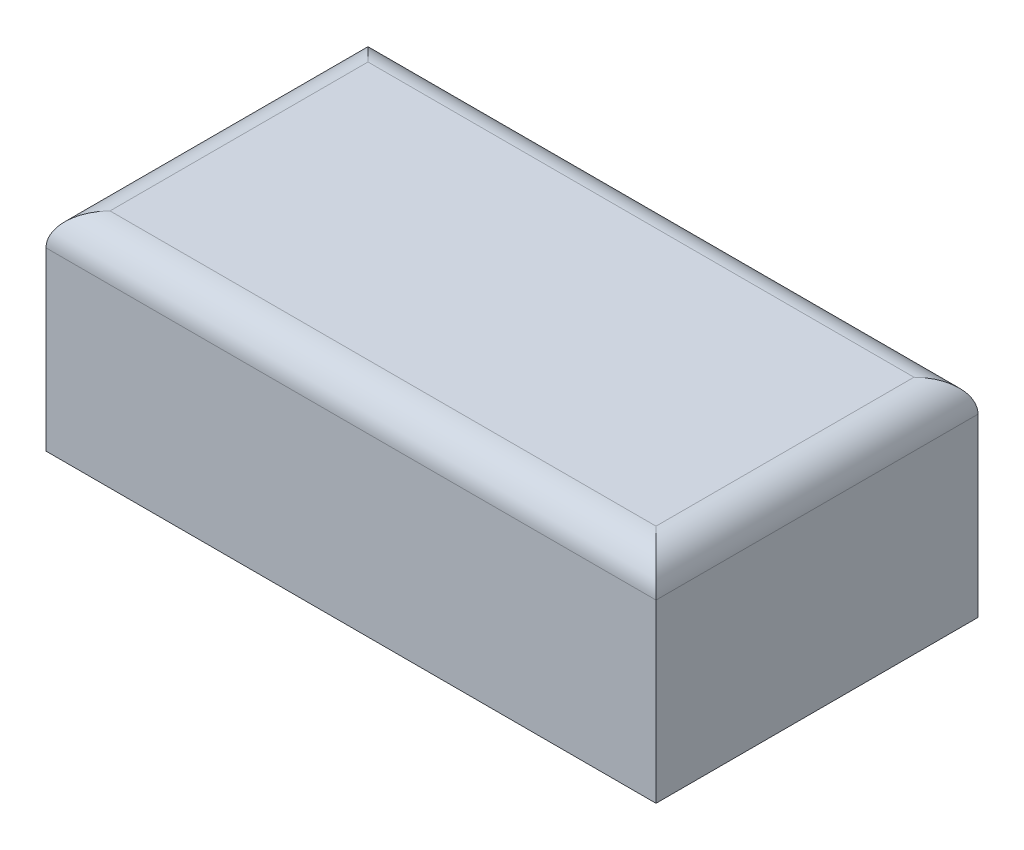
from build123d import *

# Parameters (mm, degrees)
BOSS_EXTRUDE1_START = 650
SKETCH1_W           = 1906
SKETCH1_H           = 1006
BOSS_EXTRUDE1_DEPTH = 2
SKETCH2_W           = 1906
SKETCH2_H           = 1006
SKETCH2_W_2         = 1900
SKETCH2_H_2         = 1002.833158448
BOSS_EXTRUDE2_DEPTH = 648
FILLET1_R           = 100
SKETCH3_W           = 1400
SKETCH3_H           = 560
CUT_EXTRUDE1_DEPTH  = 143


with BuildPart() as part:
    # Sketch1 → Boss-Extrude1 (new body)
    with BuildSketch(Plane(origin=(0, 0, 0), x_dir=(1, 0, 0), z_dir=(0, 1, 0)).offset(BOSS_EXTRUDE1_START)):
        Rectangle(SKETCH1_W, SKETCH1_H)
    extrude(amount=BOSS_EXTRUDE1_DEPTH)

    # Sketch2 → Boss-Extrude2 (add)
    with BuildSketch(Plane.XZ.offset(-650)):
        Rectangle(SKETCH2_W, SKETCH2_H)
        Rectangle(SKETCH2_W_2, SKETCH2_H_2, mode=Mode.SUBTRACT)
    extrude(amount=BOSS_EXTRUDE2_DEPTH)

    # Fillet1
    fillet1_edges = [part.edges().sort_by_distance(p)[0] for p in [
        (953, 652, 0),
        (0, 652, -503),
        (0, 650, 501.416579224),
        (-950, 650, 0),
        (0, 650, -501.416579224),
        (950, 650, 0),
        (-953, 652, 0),
        (0, 652, 503),
    ]]
    fillet(fillet1_edges, radius=FILLET1_R)

    # Sketch3 → Cut-Extrude1 (cut)
    with BuildSketch(Plane(origin=(0, 0, -503), x_dir=(-1, 0, 0), z_dir=(0, 0, -1))):
        with Locations((0, 2)):
            Rectangle(SKETCH3_W, SKETCH3_H)
    extrude(amount=-CUT_EXTRUDE1_DEPTH, mode=Mode.SUBTRACT)


solid = part.part
